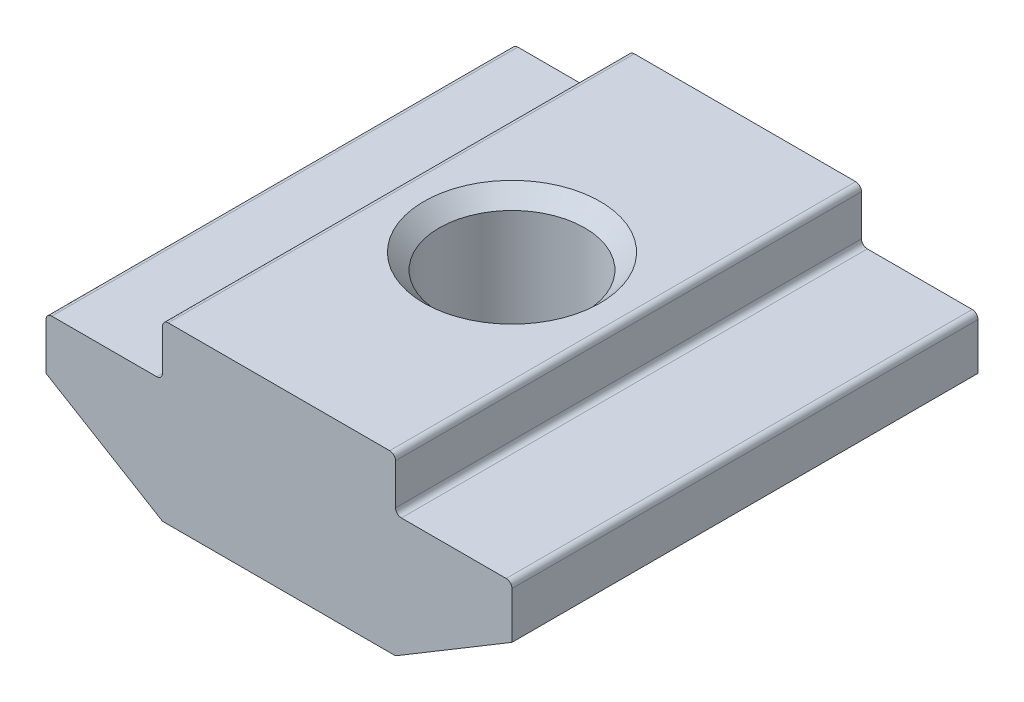
from build123d import *

# Parameters (mm, degrees)
EXTRUDE_1_DEPTH = 8
FILLET_1_R      = 0.2


with BuildPart() as part:
    # Эскиз1 → Бобышка-Вытянуть1 (new body, symmetric)
    with BuildSketch(Plane.XY):
        Polygon((4, 0), (-4, 0), (-4, -1.8), (-8, -1.8), (-8, -3.6), (-4, -6), (4, -6), (8, -3.6), (8, -1.8), (4, -1.8), align=None)
    extrude(amount=EXTRUDE_1_DEPTH, both=True)

    # Эскиз4 → Отверстие обработанное метчиком M62 (revolve, cut)
    with BuildSketch(Plane(origin=(0, 0, 0), x_dir=(0, 0, 1), z_dir=(1, 0, 0))):
        Polygon((0, 0), (0, 6), (3.025, 6), (2.5, 5.475), (2.5, 0.525), (3.025, 0), align=None)
    revolve(axis=Axis((0, 6.35, 0), (0, -1, 0)), mode=Mode.SUBTRACT)

    # Скругление1
    fillet_1_edges = [part.edges().sort_by_distance(p)[0] for p in [
        (-4, 0, 0),
        (4, 0, 0),
        (4, -1.8, 0),
        (8, -1.8, 0),
        (4, -6, 0),
        (-4, -6, 0),
        (-8, -1.8, 0),
        (-4, -1.8, 0),
    ]]
    fillet(fillet_1_edges, radius=FILLET_1_R)


solid = part.part
